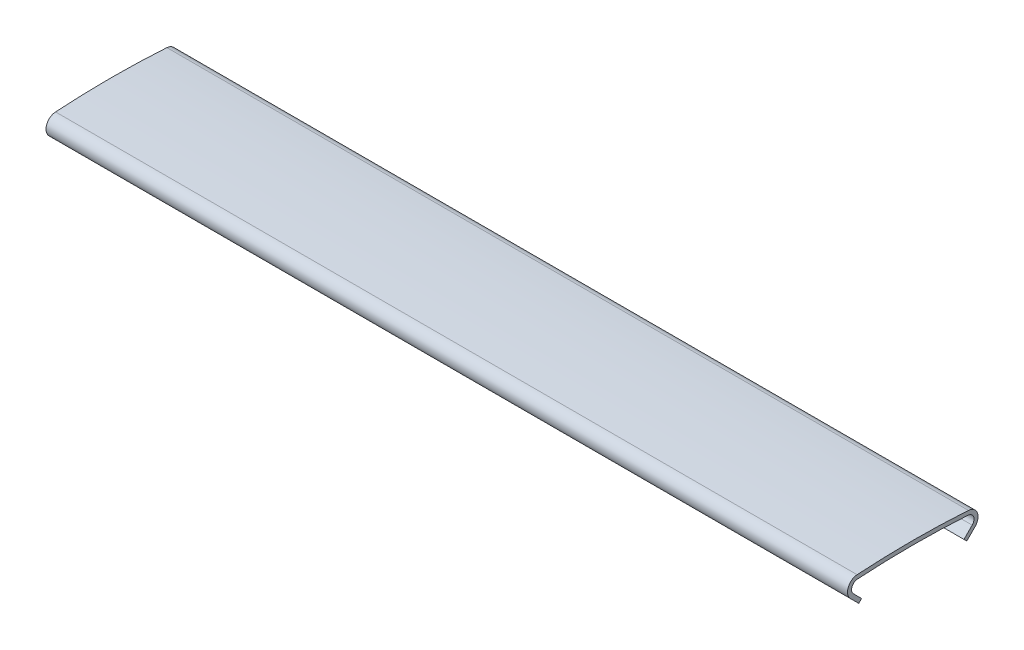
from build123d import *

# Parameters (mm, degrees)
BOSS_EXTRUDE1_DEPTH = 43


with BuildPart() as part:
    # Sketch1 → Boss-Extrude1 (new body, symmetric)
    with BuildSketch(Plane(origin=(0, 0, 0), x_dir=(0, 0, -1), z_dir=(1, 0, 0))):
        with BuildLine():
            Line((6.678248915, -2.066776115), (5.793546079, -2.951478951))
            Line((5.793546079, -2.951478951), (5.489490163, -2.647423035))
            Line((5.489490163, -2.647423035), (6.374192999, -1.762720199))
            ThreePointArc((6.374192999, -1.762720199), (6.527082765, -1.0543294), (5.944808192, -0.622879372))
            ThreePointArc((5.944808192, -0.622879372), (0, -0.43), (-5.944808192, -0.622879372))
            ThreePointArc((-5.944808192, -0.622879372), (-6.527082765, -1.0543294), (-6.374192999, -1.762720199))
            Line((-6.374192999, -1.762720199), (-5.489490163, -2.647423035))
            Line((-5.489490163, -2.647423035), (-5.793546079, -2.951478951))
            Line((-5.793546079, -2.951478951), (-6.678248915, -2.066776115))
            ThreePointArc((-6.678248915, -2.066776115), (-6.929478176, -0.902744659), (-5.97268156, -0.193783724))
            ThreePointArc((-5.97268156, -0.193783724), (0, 0), (5.97268156, -0.193783724))
            ThreePointArc((5.97268156, -0.193783724), (6.929478176, -0.902744659), (6.678248915, -2.066776115))
        make_face()
    extrude(amount=BOSS_EXTRUDE1_DEPTH, both=True)


solid = part.part
